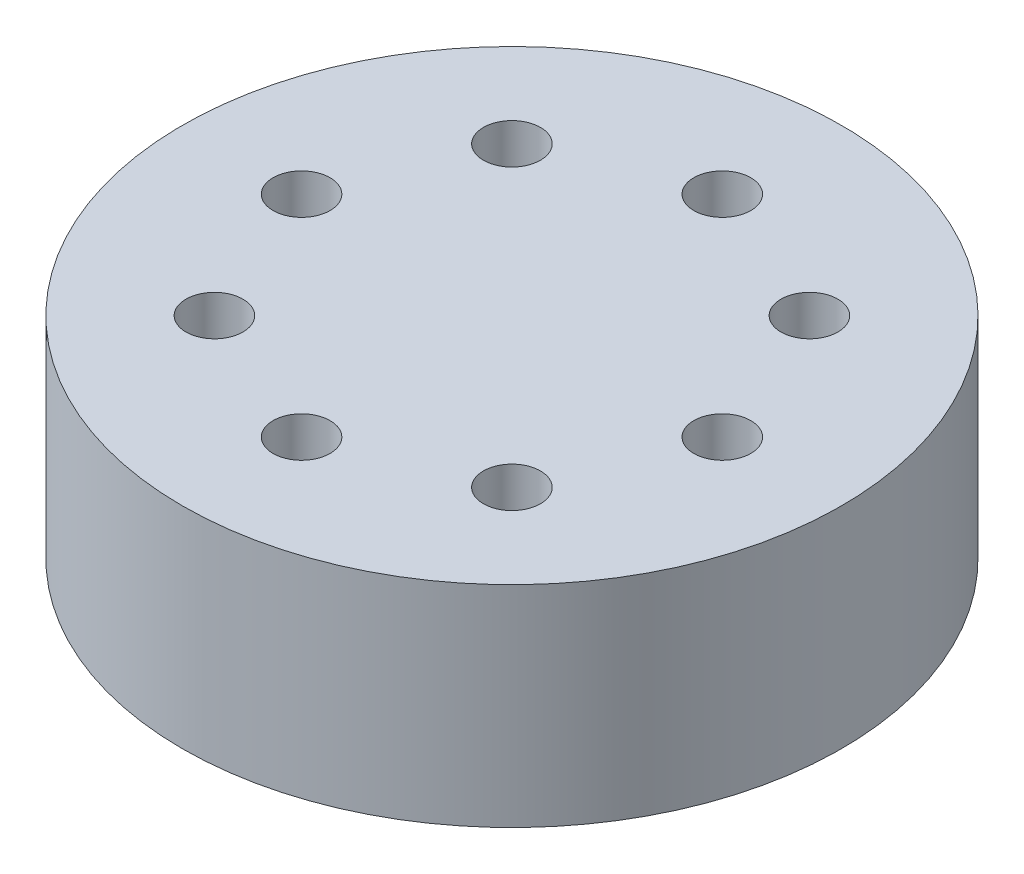
from build123d import *

# Parameters (mm, degrees)
SKETCH1_R           = 2.35
SKETCH1_R_2         = 0.2032
BOSS_EXTRUDE1_DEPTH = 1.5


with BuildPart() as part:
    # Sketch1 → Boss-Extrude1 (new body)
    with BuildSketch(Plane(origin=(0, 0, 0), x_dir=(1, 0, 0), z_dir=(0, 1, 0))):
        Circle(SKETCH1_R)
        with Locations((0, 1.5)):
            Circle(SKETCH1_R_2, mode=Mode.SUBTRACT)
        with Locations((1.060660172, 1.060660172)):
            Circle(SKETCH1_R_2, mode=Mode.SUBTRACT)
        with Locations((1.5, 0)):
            Circle(SKETCH1_R_2, mode=Mode.SUBTRACT)
        with Locations((1.060660172, -1.060660172)):
            Circle(SKETCH1_R_2, mode=Mode.SUBTRACT)
        with Locations((0, -1.5)):
            Circle(SKETCH1_R_2, mode=Mode.SUBTRACT)
        with Locations((-1.060660172, -1.060660172)):
            Circle(SKETCH1_R_2, mode=Mode.SUBTRACT)
        with Locations((-1.5, 0)):
            Circle(SKETCH1_R_2, mode=Mode.SUBTRACT)
        with Locations((-1.060660172, 1.060660172)):
            Circle(SKETCH1_R_2, mode=Mode.SUBTRACT)
    extrude(amount=BOSS_EXTRUDE1_DEPTH)


solid = part.part
